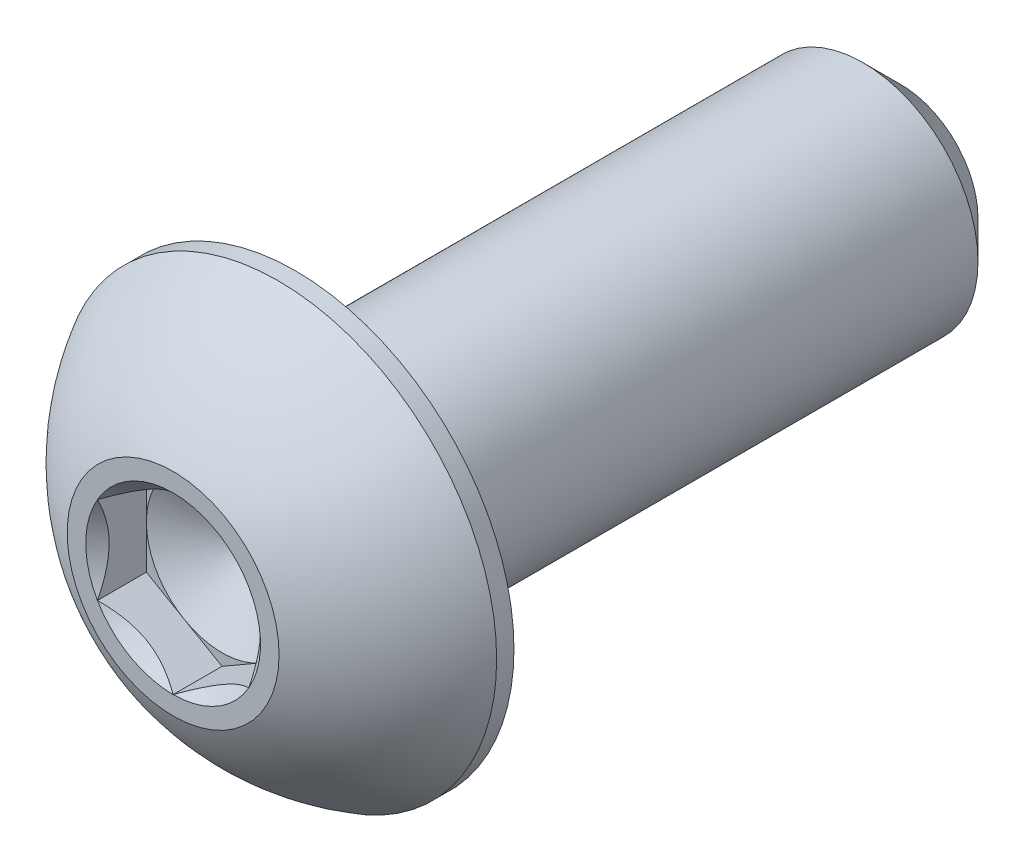
from build123d import *

# Parameters (mm, degrees)
CUT_EXTRUDE1_START = 6.60654
CUT_EXTRUDE1_DEPTH = 2.02616
SKETCH4_R          = 1.833087105
CUT_EXTRUDE2_DEPTH = 1.02616
CUT_EXTRUDE2_DRAFT = -45


with BuildPart() as part:
    # Sketch2 → Revolve1 (revolve)
    with BuildSketch(Plane(origin=(0, 0, 0), x_dir=(0, 0, -1), z_dir=(1, 0, 0))):
        with BuildLine():
            Line((-7.6327, 1.5875), (-7.6327, 2.2225))
            ThreePointArc((-7.6327, 2.2225), (-6.717752118, 3.57733025), (-5.430157143, 4.5847))
            Line((-5.430157143, 4.5847), (-5.0673, 4.5847))
            Line((-5.0673, 4.5847), (-5.0673, 2.413))
            Line((-5.0673, 2.413), (6.83895, 2.413))
            Line((6.83895, 2.413), (7.6327, 1.61925))
            Line((7.6327, 1.61925), (7.6327, 0))
            Line((7.6327, 0), (-5.689996448, 0))
            Line((-5.689996448, 0), (-6.60654, 1.5875))
            Line((-6.60654, 1.5875), (-7.6327, 1.5875))
        make_face()
    revolve(axis=Axis((0, 0, 7.6327), (0, 0, -1)))

    # Sketch3 → Cut-Extrude1 (cut, through all)
    with BuildSketch(Plane.XY.offset(CUT_EXTRUDE1_START)):
        Polygon((0, 1.833087105), (-1.5875, 0.916543552), (-1.5875, -0.916543552), (0, -1.833087105), (1.5875, -0.916543552), (1.5875, 0.916543552), align=None)
    extrude(amount=CUT_EXTRUDE1_DEPTH, mode=Mode.SUBTRACT)


with BuildPart() as cut_extrude2_tool:
    # Sketch4 → Cut-Extrude2 (with draft: the straight prism first)
    with BuildSketch(Plane.XY.offset(7.6327)):
        Circle(SKETCH4_R)
    extrude(amount=-CUT_EXTRUDE2_DEPTH)
    # Cut-Extrude2: the draft: its side faces are tilted about the plane it starts from
    cut_extrude2_sides = [cut_extrude2_tool.faces().sort_by_distance(p)[0] for p in [
        (-1.833087105, 0, 7.11962),
    ]]
    draft(cut_extrude2_sides, Plane.XY.offset(7.6327), CUT_EXTRUDE2_DRAFT)


with BuildPart() as part_1:
    add(part.part)

    # Cut-Extrude2: cut by cut_extrude2_tool
    add(cut_extrude2_tool.part, mode=Mode.SUBTRACT)


solid = part_1.part
